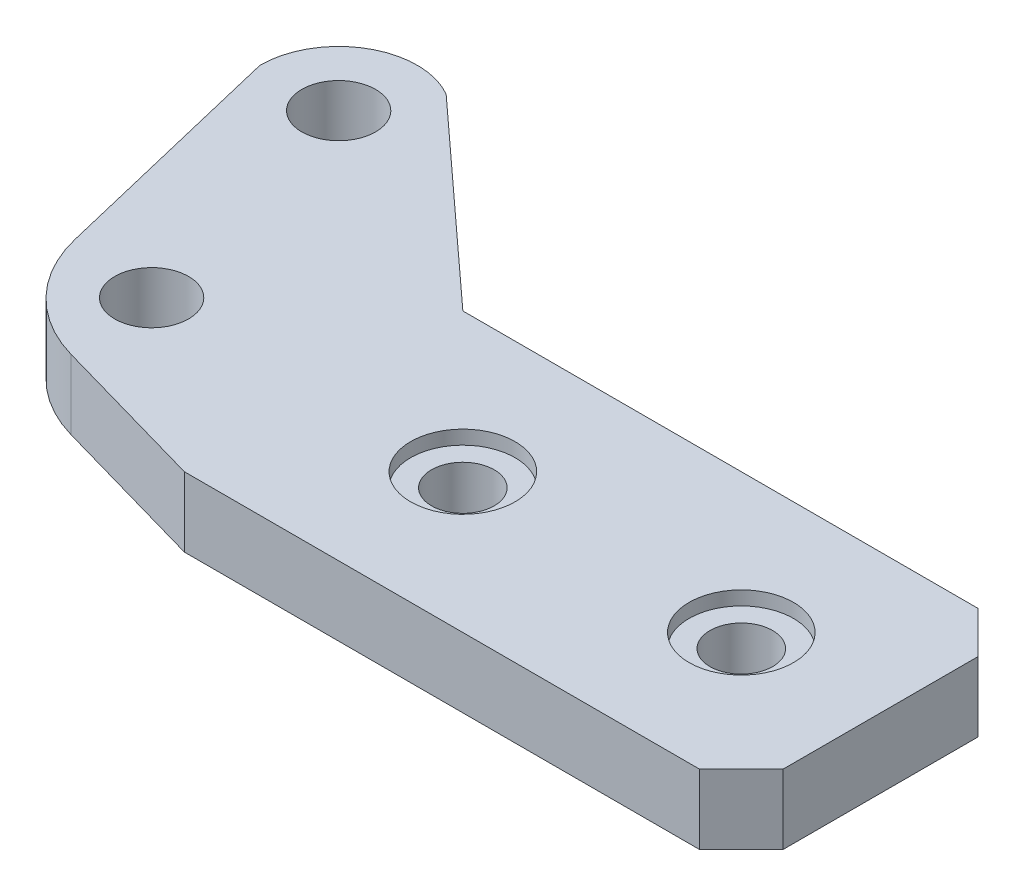
from build123d import *

# Parameters (mm, degrees)
SKETCH1_R           = 2.65
BOSS_EXTRUDE1_DEPTH = 5
CUT_EXTRUDE2_REACH  = 7
SKETCH3_R           = 2.25
FILLET1_R           = 10
SKETCH4_R           = 3.75
CUT_EXTRUDE3_DEPTH  = 1
CHAMFER1_SIZE       = 3


with BuildPart() as part:
    # Sketch1 → Boss-Extrude1 (new body)
    with BuildSketch(Plane(origin=(0, 0, 0), x_dir=(1, 0, 0), z_dir=(0, 1, 0))):
        with BuildLine():
            Line((0, 10), (40, 10))
            Line((40, 10), (40, -10))
            Line((40, -10), (0, -10))
            Line((0, -10), (-17.016791442, -5.164570129))
            Line((-17.016791442, -5.164570129), (-22.567561857, 18))
            ThreePointArc((-22.567561857, 18), (-19.742561857, 22.893043531), (-14.092561857, 22.893043531))
            Line((-14.092561857, 22.893043531), (0, 10))
        make_face()
        with Locations((-16.917561857, 18)):
            Circle(SKETCH1_R, mode=Mode.SUBTRACT)
        with Locations((-12, -0.352590699)):
            Circle(SKETCH1_R, mode=Mode.SUBTRACT)
    extrude(amount=BOSS_EXTRUDE1_DEPTH)

    # Sketch3 → Cut-Extrude2 (cut, up to next)
    with BuildSketch(Plane(origin=(0, 5, 0), x_dir=(1, 0, 0), z_dir=(0, 1, 0)), mode=Mode.PRIVATE) as cut_extrude2_sk1:
        with Locations((10, 0)):
            Circle(SKETCH3_R)
    cut_extrude2_tool1 = extrude(cut_extrude2_sk1.sketch, amount=-CUT_EXTRUDE2_REACH, mode=Mode.PRIVATE) & part.part
    add(cut_extrude2_tool1.solids().sort_by_distance((10, 5, 0))[0], mode=Mode.SUBTRACT)
    # Sketch3 → Cut-Extrude2 (cut, up to next)
    with BuildSketch(Plane(origin=(0, 5, 0), x_dir=(1, 0, 0), z_dir=(0, 1, 0)), mode=Mode.PRIVATE) as cut_extrude2_sk2:
        with Locations((30, 0)):
            Circle(SKETCH3_R)
    cut_extrude2_tool2 = extrude(cut_extrude2_sk2.sketch, amount=-CUT_EXTRUDE2_REACH, mode=Mode.PRIVATE) & part.part
    add(cut_extrude2_tool2.solids().sort_by_distance((30, 5, 0))[0], mode=Mode.SUBTRACT)

    # Fillet1
    fillet1_edges = [part.edges().sort_by_distance(p)[0] for p in [
        (-17.016791442, 2.5, 5.164570129),
    ]]
    fillet(fillet1_edges, radius=FILLET1_R)

    # Sketch4 → Cut-Extrude3 (cut)
    with BuildSketch(Plane(origin=(0, 5, 0), x_dir=(1, 0, 0), z_dir=(0, 1, 0))):
        with Locations((10, 0)):
            Circle(SKETCH4_R)
        with Locations((30, 0)):
            Circle(SKETCH4_R)
    extrude(amount=-CUT_EXTRUDE3_DEPTH, mode=Mode.SUBTRACT)

    # Chamfer1
    chamfer1_edges = [part.edges().sort_by_distance(p)[0] for p in [
        (40, 2.5, -10),
        (40, 2.5, 10),
    ]]
    chamfer(chamfer1_edges, length=CHAMFER1_SIZE)


solid = part.part
